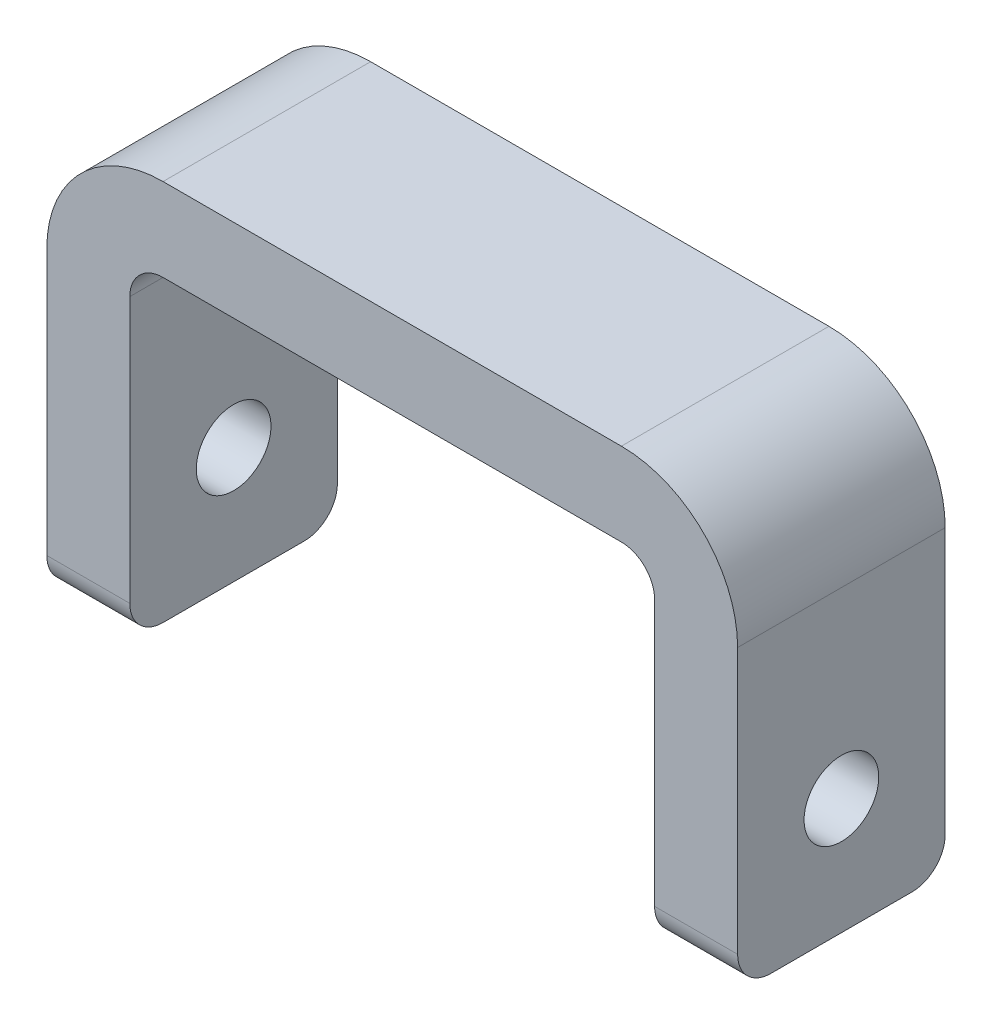
from build123d import *

# Parameters (mm, degrees)
BOSS_EXTRUDE1_DEPTH  = 6.25
FILLET1_R            = 2
FILLET2_R            = 7
FILLET3_R            = 2
M4_CLEARANCE_HOLE1_D = 4.5


with BuildPart() as part:
    # Sketch1 → Boss-Extrude1 (new body, symmetric)
    with BuildSketch(Plane.XY):
        Polygon((-15.8, 0), (-20.8, 0), (-20.8, 25), (20.8, 25), (20.8, 0), (15.8, 0), (15.8, 20), (-15.8, 20), align=None)
    extrude(amount=BOSS_EXTRUDE1_DEPTH, both=True)

    # Fillet1
    fillet1_edges = [part.edges().sort_by_distance(p)[0] for p in [
        (15.8, 20, 0),
        (-15.8, 20, 0),
    ]]
    fillet(fillet1_edges, radius=FILLET1_R)

    # Fillet2
    fillet2_edges = [part.edges().sort_by_distance(p)[0] for p in [
        (-20.8, 25, 0),
        (20.8, 25, 0),
    ]]
    fillet(fillet2_edges, radius=FILLET2_R)

    # Fillet3
    fillet3_edges = [part.edges().sort_by_distance(p)[0] for p in [
        (18.3, 0, -6.25),
        (18.3, 0, 6.25),
        (-18.3, 0, 6.25),
        (-18.3, 0, -6.25),
    ]]
    fillet(fillet3_edges, radius=FILLET3_R)

    # M4 Clearance Hole1 (through all)
    with Locations(Plane.ZY.offset(20.8)):
        with Locations((0, 7)):
            Hole(M4_CLEARANCE_HOLE1_D / 2)


solid = part.part
